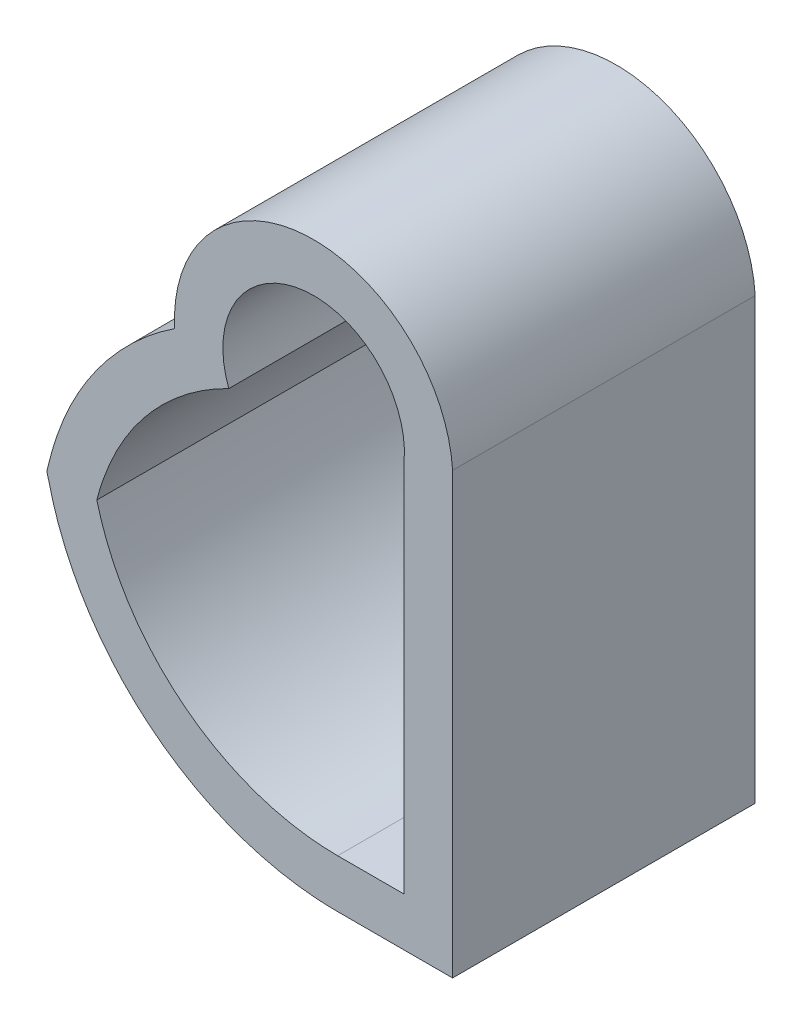
from build123d import *

# Parameters (mm, degrees)
BOSS_EXTRUDE1_DEPTH = 5


with BuildPart() as part:
    # Sketch1 → Boss-Extrude1 (new body)
    with BuildSketch(Plane.XY):
        with BuildLine():
            ThreePointArc((-75.265428178, 20.9), (-75.130279043, 20.511046865), (-75.105982855, 20.1))
            Line((-75.105982855, 20.1), (-75.105982855, 19.853719883))
            add(Edge.make_bspline(
                [(-74.305982855, 19.570019979), (-74.57545788, 19.689791559), (-74.842109989, 19.784227542), (-75.105982855, 19.853719883)],
                knots=[-0.347916047, -0.347916047, -0.347916047, -0.347916047, -0.203467167, -0.203467167, -0.203467167, -0.203467167], degree=3))
            Line((-74.305982855, 19.570019979), (-74.305982855, 20.071878785))
            Line((-74.305982855, 20.071878785), (-74.305982855, 20.363828129))
            ThreePointArc((-74.305982855, 20.363828129), (-74.339463682, 20.634853388), (-74.404831342, 20.9))
            Line((-74.404831342, 20.9), (-75.265428178, 20.9))
        make_face()
        with BuildLine():
            add(Edge.make_bspline(
                [(-74.305982855, 19.570019979), (-74.57545788, 19.689791559), (-74.842109989, 19.784227542), (-75.105982855, 19.853719883)],
                knots=[-0.347916047, -0.347916047, -0.347916047, -0.347916047, -0.203467167, -0.203467167, -0.203467167, -0.203467167], degree=3))
            Line((-75.105982855, 19.853719883), (-75.105982855, 16.984329869))
            Line((-75.105982855, 16.984329869), (-75.105982855, 14.140403881))
            add(Edge.make_bspline(
                [(-75.105982855, 14.140403881), (-74.843255413, 14.206157854), (-74.576591527, 14.295030515), (-74.305982855, 14.407070854)],
                knots=[1.201768628, 1.201768628, 1.201768628, 1.201768628, 1.343435707, 1.343435707, 1.343435707, 1.343435707], degree=3))
            Line((-74.305982855, 14.407070854), (-74.305982855, 17.699135935))
            Line((-74.305982855, 17.699135935), (-74.305982855, 19.570019979))
        make_face()
        with BuildLine():
            ThreePointArc((-78.067947351, 20.532623393), (-76.79630986, 21.70512917), (-75.265428178, 20.9))
            Line((-75.265428178, 20.9), (-74.404831342, 20.9))
            ThreePointArc((-74.404831342, 20.9), (-77.006960237, 22.481805089), (-78.898061562, 20.094983372))
            add(Edge.make_bspline(
                [(-78.067947351, 20.532623393), (-78.358359688, 20.413646492), (-78.636457372, 20.266940111), (-78.898061562, 20.094983372)],
                knots=[0.295059063, 0.295059063, 0.295059063, 0.295059063, 0.440738585, 0.440738585, 0.440738585, 0.440738585], degree=3))
        make_face()
        with BuildLine():
            add(Edge.make_bspline(
                [(-78.003515184, 19.685010862), (-78.104869219, 19.63560007), (-78.355344555, 19.500363503), (-78.967656438, 19.082169769), (-79.659987233, 18.331266584), (-80.013929538, 17.564650836), (-80.12711921, 17.200243393)],
                knots=[0.344074201, 0.344074201, 0.344074201, 0.344074201, 0.406881084, 0.502455065, 0.753682598, 0.966213979, 0.966213979, 0.966213979, 0.966213979], degree=3))
            ThreePointArc((-78.003515184, 19.685010862), (-78.097030736, 20.104157384), (-78.067947351, 20.532623393))
            add(Edge.make_bspline(
                [(-78.067947351, 20.532623393), (-78.358359688, 20.413646492), (-78.636457372, 20.266940111), (-78.898061562, 20.094983372)],
                knots=[0.295059063, 0.295059063, 0.295059063, 0.295059063, 0.440738585, 0.440738585, 0.440738585, 0.440738585], degree=3))
            add(Edge.make_bspline(
                [(-78.898061562, 20.094983372), (-79.044158498, 19.998951452), (-79.506474474, 19.658143157), (-79.905620688, 19.237259361), (-80.14350503, 18.917192132)],
                knots=[0.440738585, 0.440738585, 0.440738585, 0.440738585, 0.522095585, 0.707584074, 0.707584074, 0.707584074, 0.707584074], degree=3))
            add(Edge.make_bspline(
                [(-80.143505006, 18.917192121), (-80.243393446, 18.301629507), (-80.235757559, 17.730205674), (-80.12711921, 17.200243393)],
                knots=[-0.342301016, -0.342301016, -0.342301016, -0.342301016, -0.038630201, -0.038630201, -0.038630201, -0.038630201], degree=3))
        make_face()
        with BuildLine():
            add(Edge.make_bspline(
                [(-80.12711921, 17.200243393), (-80.147727954, 17.133894765), (-80.166711829, 17.067112434), (-80.184053986, 17)],
                knots=[0.966213979, 0.966213979, 0.966213979, 0.966213979, 1.00491013, 1.00491013, 1.00491013, 1.00491013], degree=3))
            add(Edge.make_bspline(
                [(-80.143505006, 18.917192121), (-80.243393446, 18.301629507), (-80.235757559, 17.730205674), (-80.12711921, 17.200243393)],
                knots=[-0.342301016, -0.342301016, -0.342301016, -0.342301016, -0.038630201, -0.038630201, -0.038630201, -0.038630201], degree=3))
            add(Edge.make_bspline(
                [(-80.14350503, 18.917192132), (-80.240407946, 18.786811765), (-80.486796547, 18.418759671), (-80.740911848, 17.89685783), (-80.901091234, 17.421401242), (-80.969166274, 17.159575272), (-80.996010355, 17.055421709), (-81.010331575, 17)],
                knots=[0.707584074, 0.707584074, 0.707584074, 0.707584074, 0.783143378, 0.913667274, 0.978929222, 1.011560196, 1.044191171, 1.044191171, 1.044191171, 1.044191171], degree=3))
            add(Edge.make_bspline(
                [(-81.010331575, 17), (-80.995912214, 16.944198497), (-80.968881368, 16.839270604), (-80.900356676, 16.576013924), (-80.741671714, 16.105170367), (-80.311695813, 15.221571956), (-79.37871474, 14.137722448), (-77.891914282, 13.2952625), (-76.763881291, 13.1), (-76.204616771, 13.1)],
                knots=[-0.043877202, -0.043877202, -0.043877202, -0.043877202, -0.011256039, 0.021365123, 0.086607448, 0.217092099, 0.478061399, 0.7390307, 1, 1, 1, 1], degree=3))
            Line((-76.204616771, 13.1), (-74.305982855, 13.1))
            Line((-74.305982855, 13.1), (-74.305982855, 14.407070854))
            add(Edge.make_bspline(
                [(-75.105982855, 14.140403881), (-74.843255413, 14.206157854), (-74.576591527, 14.295030515), (-74.305982855, 14.407070854)],
                knots=[1.201768628, 1.201768628, 1.201768628, 1.201768628, 1.343435707, 1.343435707, 1.343435707, 1.343435707], degree=3))
            Line((-75.105982855, 14.140403881), (-75.105982855, 13.9))
            Line((-75.105982855, 13.9), (-76.204616771, 13.9))
            add(Edge.make_bspline(
                [(-78.772417568, 14.802007342), (-78.757445413, 14.790011818), (-78.387128598, 14.497563572), (-77.563800223, 14.051022081), (-76.655306258, 13.9), (-76.204616771, 13.9)],
                knots=[0.48691566, 0.48691566, 0.48691566, 0.48691566, 0.497562378, 0.748781189, 1, 1, 1, 1], degree=3))
            add(Edge.make_bspline(
                [(-80.126958505, 16.799254372), (-80.350350695, 15.691334532), (-80.041454579, 14.614718165), (-78.772417566, 14.802007352)],
                knots=[1.039358775, 1.039358775, 1.039358775, 1.039358775, 1.69125552, 1.69125552, 1.69125552, 1.69125552], degree=3))
            add(Edge.make_bspline(
                [(-80.184053986, 17), (-80.166668157, 16.932718561), (-80.147630382, 16.865768509), (-80.126958505, 16.799254372)],
                knots=[-0.004875245, -0.004875245, -0.004875245, -0.004875245, 0.033874117, 0.033874117, 0.033874117, 0.033874117], degree=3))
        make_face()
        with BuildLine():
            add(Edge.make_bspline(
                [(-80.126958505, 16.799254372), (-80.01361103, 16.434545856), (-79.667166625, 15.684835242), (-79.110726777, 15.07305693), (-78.772417568, 14.802007342)],
                knots=[0.033874117, 0.033874117, 0.033874117, 0.033874117, 0.246343567, 0.48691566, 0.48691566, 0.48691566, 0.48691566], degree=3))
            add(Edge.make_bspline(
                [(-80.126958505, 16.799254372), (-80.350350695, 15.691334532), (-80.041454579, 14.614718165), (-78.772417566, 14.802007352)],
                knots=[1.039358775, 1.039358775, 1.039358775, 1.039358775, 1.69125552, 1.69125552, 1.69125552, 1.69125552], degree=3))
        make_face()
    extrude(amount=BOSS_EXTRUDE1_DEPTH)


solid = part.part
